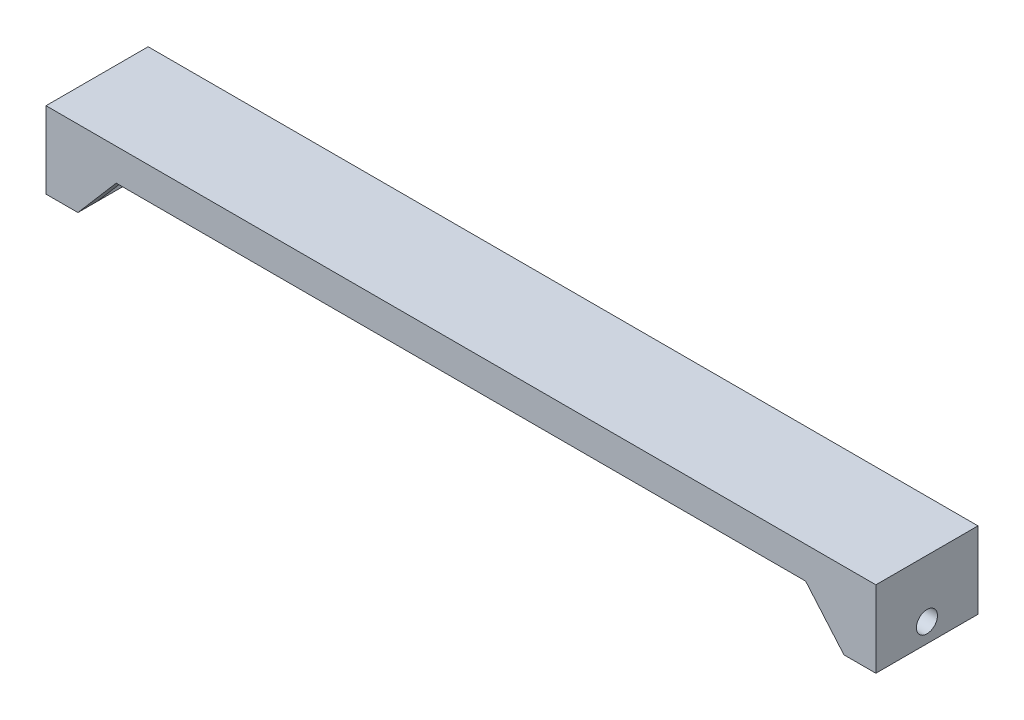
from build123d import *

# Parameters (mm, degrees)
EXTRUDE_2_DEPTH          = 16
SKETCH_3_R               = 1.65
CUT_EXTRUDE_1_DEPTH      = 126
CUT_EXTRUDE_1_DEPTH_BACK = 6
EXTRUDE_3_DEPTH          = 3
MIRROR_2_COPY_1_DEPTH    = 3


with BuildPart() as part:
    # 草图1 → 凸台-拉伸2 (new body)
    with BuildSketch(Plane.XY):
        Polygon((-65, 0), (65, 0), (65, -12), (60, -12), (60, -5), (-60, -5), (-60, -12), (-65, -12), align=None)
    extrude(amount=EXTRUDE_2_DEPTH)

    # 草图3 → 切除-拉伸1 (cut, two sides)
    with BuildSketch(Plane(origin=(-60, 0, 0), x_dir=(0, 0, -1), z_dir=(1, 0, 0))) as cut_extrude_1_sk:
        with Locations((-8, -9)):
            Circle(SKETCH_3_R)
    extrude(amount=CUT_EXTRUDE_1_DEPTH, mode=Mode.SUBTRACT)
    extrude(cut_extrude_1_sk.sketch, amount=-CUT_EXTRUDE_1_DEPTH_BACK, mode=Mode.SUBTRACT)

    # 草图4 → 凸台-拉伸3 (add)
    with BuildSketch(Plane(origin=(0, 0, 0), x_dir=(-1, 0, 0), z_dir=(0, 0, -1))):
        Polygon((54, -5), (60, -12), (60, -5), align=None)
    extrude_3 = extrude(amount=-EXTRUDE_3_DEPTH)

    # 镜向1: 凸台-拉伸3 across plane
    add(extrude_3.mirror(Plane.XY.offset(8)))

    # 镜向2: 凸台-拉伸3 across plane
    add(extrude_3.mirror(Plane(origin=(0, 0, 0), x_dir=(0, 0, 1), z_dir=(1, 0, 0))))

    # 镜向2 copy 1 sketch → 镜向2 copy 1 (add)
    with BuildSketch(Plane.XY.offset(16)):
        Polygon((54, -5), (60, -12), (60, -5), align=None)
    extrude(amount=-MIRROR_2_COPY_1_DEPTH)


solid = part.part
